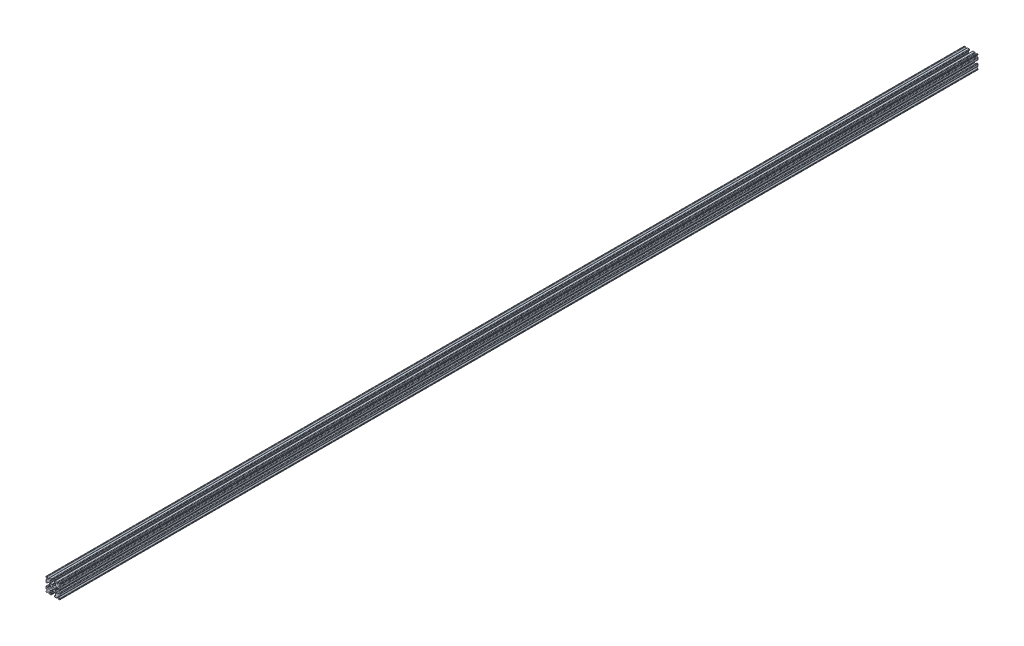
from build123d import *

# Parameters (mm, degrees)
SKETCH1_W           = 15
SKETCH1_H           = 15
SKETCH1_R           = 1.25
BOSS_EXTRUDE1_DEPTH = 500
FILLET1_R           = 0.25
CUT_EXTRUDE1_DEPTH  = 1001
CUT_EXTRUDE3_DEPTH  = 1001
FILLET3_R           = 0.5
FILLET4_R           = 0.5
FILLET5_R           = 3
FILLET6_R           = 0.2
CUT_EXTRUDE4_DEPTH  = 1001
FILLET8_R           = 0.5
SKETCH6_W           = 5.1529354
SKETCH6_H           = 1.651
SKETCH6_W_2         = 1.651
SKETCH6_H_2         = 5.1529354
CUT_EXTRUDE5_DEPTH  = 1001
FILLET10_R          = 0.2


with BuildPart() as part:
    # Sketch1 → Boss-Extrude1 (new body, symmetric)
    with BuildSketch(Plane.XY):
        Rectangle(SKETCH1_W, SKETCH1_H)
        Circle(SKETCH1_R, mode=Mode.SUBTRACT)
    extrude(amount=BOSS_EXTRUDE1_DEPTH, both=True)

    # Fillet1
    fillet1_edges = [part.edges().sort_by_distance(p)[0] for p in [
        (7.5, -7.5, 0),
        (-7.5, -7.5, 0),
        (-7.5, 7.5, 0),
        (7.5, 7.5, 0),
    ]]
    fillet(fillet1_edges, radius=FILLET1_R)

    # Sketch2 → Cut-Extrude1 (cut, through all)
    with BuildSketch(Plane.XY.offset(500)):
        Polygon((-7.5, 1.6), (-6.1, 1.6), (-6.1, 2.9), (-3.4, 2.9), (-3.4, -2.9), (-6.1, -2.9), (-6.1, -1.6), (-7.5, -1.6), align=None)
        Polygon((2.9, 6.1), (1.6, 6.1), (1.6, 7.5), (-1.6, 7.5), (-1.6, 6.1), (-2.9, 6.1), (-2.9, 3.4), (2.9, 3.4), align=None)
        Polygon((-1.6, -7.5), (-1.6, -6.1), (-2.9, -6.1), (-2.9, -3.4), (2.9, -3.4), (2.9, -6.1), (1.6, -6.1), (1.6, -7.5), align=None)
        Polygon((6.1, -2.9), (6.1, -1.6), (7.5, -1.6), (7.5, 1.6), (6.1, 1.6), (6.1, 2.9), (3.4, 2.9), (3.4, -2.9), align=None)
    extrude(amount=-CUT_EXTRUDE1_DEPTH, mode=Mode.SUBTRACT)

    # Sketch4 → Cut-Extrude3 (cut, through all)
    with BuildSketch(Plane.XY.offset(500)):
        Polygon((-3.4, 2.9), (-2.75, 0), (-3.4, -2.9), align=None)
        Polygon((-2.9, 3.4), (0, 2.75), (2.9, 3.4), align=None)
        Polygon((3.4, 2.9), (2.75, 0), (3.4, -2.9), align=None)
        Polygon((-2.9, -3.4), (0, -2.75), (2.9, -3.4), align=None)
    extrude(amount=-CUT_EXTRUDE3_DEPTH, mode=Mode.SUBTRACT)

    # Fillet3
    fillet3_edges = [part.edges().sort_by_distance(p)[0] for p in [
        (1.6, -7.5, 0),
        (-1.6, -7.5, 0),
        (-1.6, -6.1, 0),
        (1.6, -6.1, 0),
        (6.1, 1.6, 0),
        (7.5, 1.6, 0),
        (7.5, -1.6, 0),
        (6.1, -1.6, 0),
        (-7.5, -1.6, 0),
        (-7.5, 1.6, 0),
        (-6.1, 1.6, 0),
        (-6.1, -1.6, 0),
        (-1.6, 6.1, 0),
        (-1.6, 7.5, 0),
        (1.6, 7.5, 0),
        (1.6, 6.1, 0),
    ]]
    fillet(fillet3_edges, radius=FILLET3_R)

    # Fillet4
    fillet4_edges = [part.edges().sort_by_distance(p)[0] for p in [
        (-2.9, -3.4, 0),
        (2.9, -3.4, 0),
        (3.4, -2.9, 0),
        (3.4, 2.9, 0),
        (-3.4, 2.9, 0),
        (-3.4, -2.9, 0),
        (2.9, 3.4, 0),
        (-2.9, 3.4, 0),
    ]]
    fillet(fillet4_edges, radius=FILLET4_R)

    # Fillet5
    fillet5_edges = [part.edges().sort_by_distance(p)[0] for p in [
        (-2.75, 0, 0),
        (0, 2.75, 0),
        (2.75, 0, 0),
        (0, -2.75, 0),
    ]]
    fillet(fillet5_edges, radius=FILLET5_R)

    # Fillet6
    fillet6_edges = [part.edges().sort_by_distance(p)[0] for p in [
        (-2.9, -6.1, 0),
        (2.9, -6.1, 0),
        (6.1, -2.9, 0),
        (6.1, 2.9, 0),
        (-6.1, 2.9, 0),
        (-6.1, -2.9, 0),
        (2.9, 6.1, 0),
        (-2.9, 6.1, 0),
    ]]
    fillet(fillet6_edges, radius=FILLET6_R)

    # Sketch5 → Cut-Extrude4 (cut, through all)
    with BuildSketch(Plane.XY.offset(500)):
        Polygon((-7.5, 6.439339828), (-5.460660172, 4.4), (-7.5, 4.4), align=None)
        Polygon((-6.439339828, 7.5), (-4.4, 5.460660172), (-4.4, 7.5), align=None)
        Polygon((4.4, 7.5), (6.439339828, 7.5), (4.4, 5.460660172), align=None)
        Polygon((7.5, 6.439339828), (7.5, 4.4), (5.460660172, 4.4), align=None)
        Polygon((7.5, -6.439339828), (5.460660172, -4.4), (7.5, -4.4), align=None)
        Polygon((6.439339828, -7.5), (4.4, -5.460660172), (4.4, -7.5), align=None)
        Polygon((-4.4, -7.5), (-6.439339828, -7.5), (-4.4, -5.460660172), align=None)
        Polygon((-7.5, -6.439339828), (-7.5, -4.4), (-5.460660172, -4.4), align=None)
    extrude(amount=-CUT_EXTRUDE4_DEPTH, mode=Mode.SUBTRACT)

    # Fillet8
    fillet8_edges = [part.edges().sort_by_distance(p)[0] for p in [
        (-7.5, 4.4, 0),
        (-7.5, 6.439339828, 0),
        (-5.460660172, 4.4, 0),
        (7.5, -4.4, 0),
        (7.5, -6.439339828, 0),
        (5.460660172, -4.4, 0),
        (5.460660172, 4.4, 0),
        (7.5, 6.439339828, 0),
        (7.5, 4.4, 0),
        (-4.4, 7.5, 0),
        (-4.4, 5.460660172, 0),
        (-6.439339828, 7.5, 0),
        (-5.460660172, -4.4, 0),
        (-7.5, -6.439339828, 0),
        (-7.5, -4.4, 0),
        (4.4, 5.460660172, 0),
        (4.4, 7.5, 0),
        (6.439339828, 7.5, 0),
        (6.439339828, -7.5, 0),
        (4.4, -7.5, 0),
        (4.4, -5.460660172, 0),
        (-6.439339828, -7.5, 0),
        (-4.4, -5.460660172, 0),
        (-4.4, -7.5, 0),
    ]]
    fillet(fillet8_edges, radius=FILLET8_R)

    # Sketch6 → Cut-Extrude5 (cut, through all)
    with BuildSketch(Plane.XY.offset(500)):
        with Locations((4.9235323, 0)):
            Rectangle(SKETCH6_W, SKETCH6_H)
        with Locations((0, -4.9235323)):
            Rectangle(SKETCH6_W_2, SKETCH6_H_2)
        with Locations((-4.9235323, 0)):
            Rectangle(SKETCH6_W, SKETCH6_H)
        with Locations((0, 4.9235323)):
            Rectangle(SKETCH6_W_2, SKETCH6_H_2)
    extrude(amount=-CUT_EXTRUDE5_DEPTH, mode=Mode.SUBTRACT)

    # Fillet10
    fillet10_edges = [part.edges().sort_by_distance(p)[0] for p in [
        (0.8255, -2.935025862, 0),
        (-0.8255, -2.935025862, 0),
        (0.8255, -2.3470646, 0),
        (-0.8255, -2.3470646, 0),
        (2.935025862, 0.8255, 0),
        (2.935025862, -0.8255, 0),
        (2.3470646, 0.8255, 0),
        (2.3470646, -0.8255, 0),
        (-2.935025862, -0.8255, 0),
        (-2.935025862, 0.8255, 0),
        (-2.3470646, -0.8255, 0),
        (-2.3470646, 0.8255, 0),
        (-0.8255, 2.935025862, 0),
        (0.8255, 2.935025862, 0),
        (-0.8255, 2.3470646, 0),
        (0.8255, 2.3470646, 0),
    ]]
    fillet(fillet10_edges, radius=FILLET10_R)


solid = part.part
